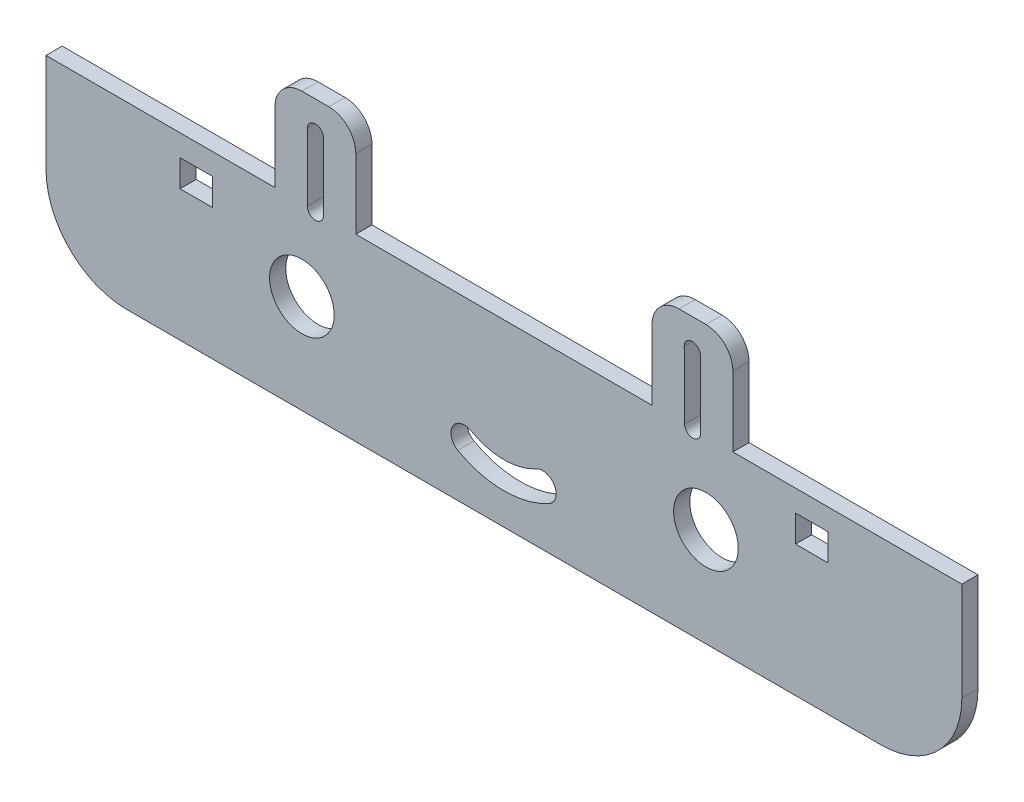
from build123d import *

# Parameters (mm, degrees)
BOSS_EXTRUDE1_DEPTH = 3
FILLET2_R           = 5
SKETCH3_R           = 6
CUT_EXTRUDE1_DEPTH  = 10
SKETCH4_W           = 6
SKETCH4_H           = 5
CUT_EXTRUDE2_DEPTH  = 10


with BuildPart() as part:
    # Sketch1 → Boss-Extrude1 (new body)
    with BuildSketch(Plane.XY):
        with BuildLine():
            Line((-103.55358225, -48), (-61.05358225, -48))
            Line((-61.05358225, -48), (-61.05358225, -30))
            Line((-61.05358225, -30), (-46.05358225, -30))
            Line((-46.05358225, -30), (-46.05358225, -48))
            Line((-46.05358225, -48), (8.94641775, -48))
            Line((8.94641775, -48), (8.94641775, -30))
            Line((8.94641775, -30), (23.94641775, -30))
            Line((23.94641775, -30), (23.94641775, -48))
            Line((23.94641775, -48), (66.44641775, -48))
            Line((66.44641775, -48), (66.44641775, -66.348486101))
            ThreePointArc((66.44641775, -66.348486101), (62.053019468, -76.955087819), (51.44641775, -81.348486101))
            Line((51.44641775, -81.348486101), (-88.55358225, -81.348486101))
            ThreePointArc((-88.55358225, -81.348486101), (-99.160183967, -76.955087819), (-103.55358225, -66.348486101))
            Line((-103.55358225, -66.348486101), (-103.55358225, -48))
        make_face()
        with BuildLine():
            Line((-55.05358225, -48.000000021), (-55.05358225, -35.500000021))
            ThreePointArc((-55.05358225, -35.500000021), (-53.55358225, -34.000000021), (-52.05358225, -35.500000021))
            Line((-52.05358225, -35.500000021), (-52.05358225, -48.000000021))
            ThreePointArc((-52.05358225, -48.000000021), (-53.55358225, -49.500000021), (-55.05358225, -48.000000021))
        make_face(mode=Mode.SUBTRACT)
        with BuildLine():
            Line((14.97417929, -48.006597652), (14.918685775, -35.506720833))
            ThreePointArc((14.918685775, -35.506720833), (16.412011771, -34.000076394), (17.918656211, -35.49340239))
            Line((17.918656211, -35.49340239), (17.974149726, -47.993279208))
            ThreePointArc((17.974149726, -47.993279208), (16.48082373, -49.499923648), (14.97417929, -48.006597652))
        make_face(mode=Mode.SUBTRACT)
    extrude(amount=BOSS_EXTRUDE1_DEPTH)

    # Fillet2
    fillet2_edges = [part.edges().sort_by_distance(p)[0] for p in [
        (-61.05358225, -30, 1.5),
        (-46.05358225, -30, 1.5),
        (8.94641775, -30, 1.5),
        (23.94641775, -30, 1.5),
    ]]
    fillet(fillet2_edges, radius=FILLET2_R)

    # Sketch3 → Cut-Extrude1 (cut)
    with BuildSketch(Plane.XY.offset(3)):
        with Locations((-56.05358225, -63)):
            Circle(SKETCH3_R)
        with Locations((18.94641775, -63)):
            Circle(SKETCH3_R)
        with BuildLine():
            ThreePointArc((-27.106412897, -73.26758291), (-18.643210609, -75.499770477), (-10.157587782, -73.354389499))
            ThreePointArc((-10.157587782, -73.354389499), (-9.163531348, -69.961477504), (-12.556443344, -68.967421071))
            ThreePointArc((-12.556443344, -68.967421071), (-18.617602506, -70.499836055), (-24.662746998, -68.905416364))
            ThreePointArc((-24.662746998, -68.905416364), (-28.06566322, -69.864666688), (-27.106412897, -73.26758291))
        make_face()
    extrude(amount=-CUT_EXTRUDE1_DEPTH, mode=Mode.SUBTRACT)

    # Sketch4 → Cut-Extrude2 (cut)
    with BuildSketch(Plane.XY.offset(3)):
        with Locations((38.567805477, -54.5)):
            Rectangle(SKETCH4_W, SKETCH4_H)
        with Locations((-75.674969976, -54.5)):
            Rectangle(SKETCH4_W, SKETCH4_H)
    extrude(amount=-CUT_EXTRUDE2_DEPTH, mode=Mode.SUBTRACT)


solid = part.part
